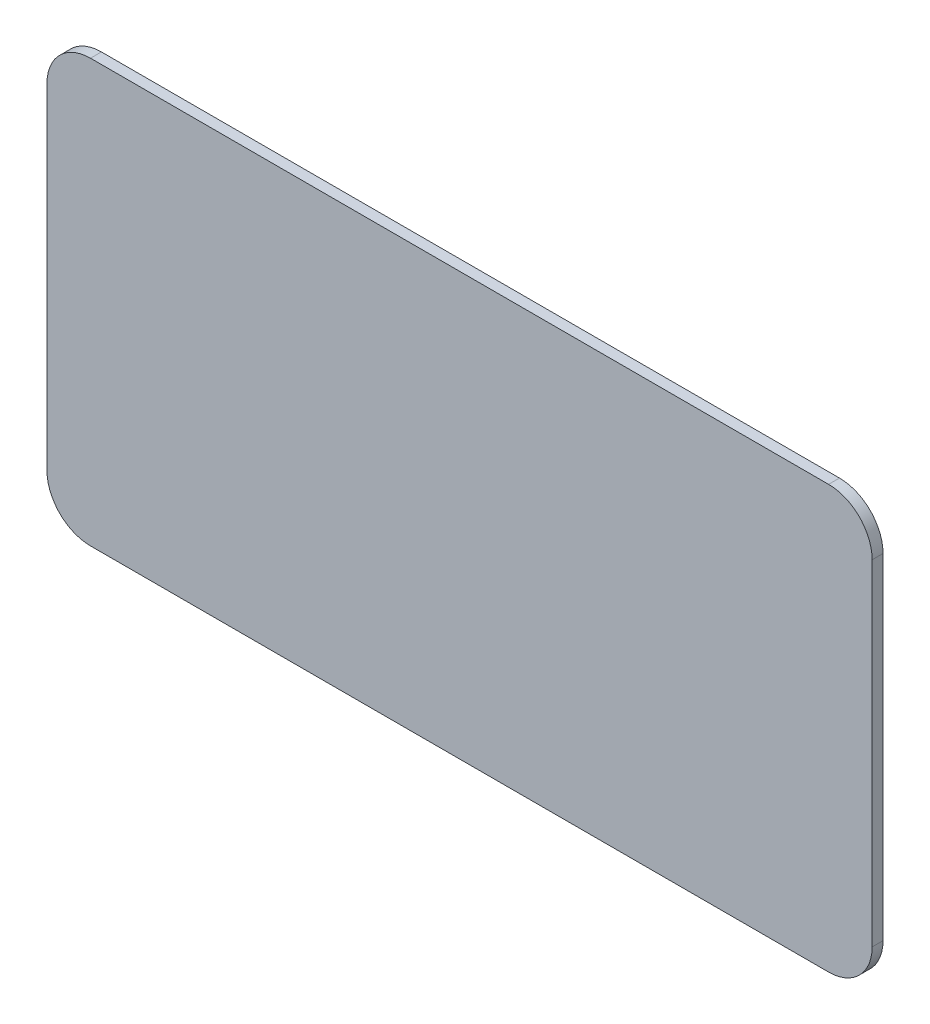
from build123d import *

# Parameters (mm, degrees)
SKETCH_1_W      = 758
SKETCH_1_H      = 388
EXTRUDE_1_DEPTH = 10
FILLET_1_R      = 40
FILLET_2_R      = 40
FILLET_3_R      = 40
FILLET_4_R      = 40


with BuildPart() as part:
    # 草图1 → 凸台-拉伸1 (new body)
    with BuildSketch(Plane.XY):
        with Locations((379, 194)):
            Rectangle(SKETCH_1_W, SKETCH_1_H)
    extrude(amount=EXTRUDE_1_DEPTH)

    # 圆角1
    fillet_1_edges = [part.edges().sort_by_distance(p)[0] for p in [
        (758, 388, 5),
    ]]
    fillet(fillet_1_edges, radius=FILLET_1_R)

    # 圆角2
    fillet_2_edges = [part.edges().sort_by_distance(p)[0] for p in [
        (758, 0, 5),
    ]]
    fillet(fillet_2_edges, radius=FILLET_2_R)

    # 圆角3
    fillet_3_edges = [part.edges().sort_by_distance(p)[0] for p in [
        (0, 0, 5),
    ]]
    fillet(fillet_3_edges, radius=FILLET_3_R)

    # 圆角4
    fillet_4_edges = [part.edges().sort_by_distance(p)[0] for p in [
        (0, 388, 5),
    ]]
    fillet(fillet_4_edges, radius=FILLET_4_R)


solid = part.part
